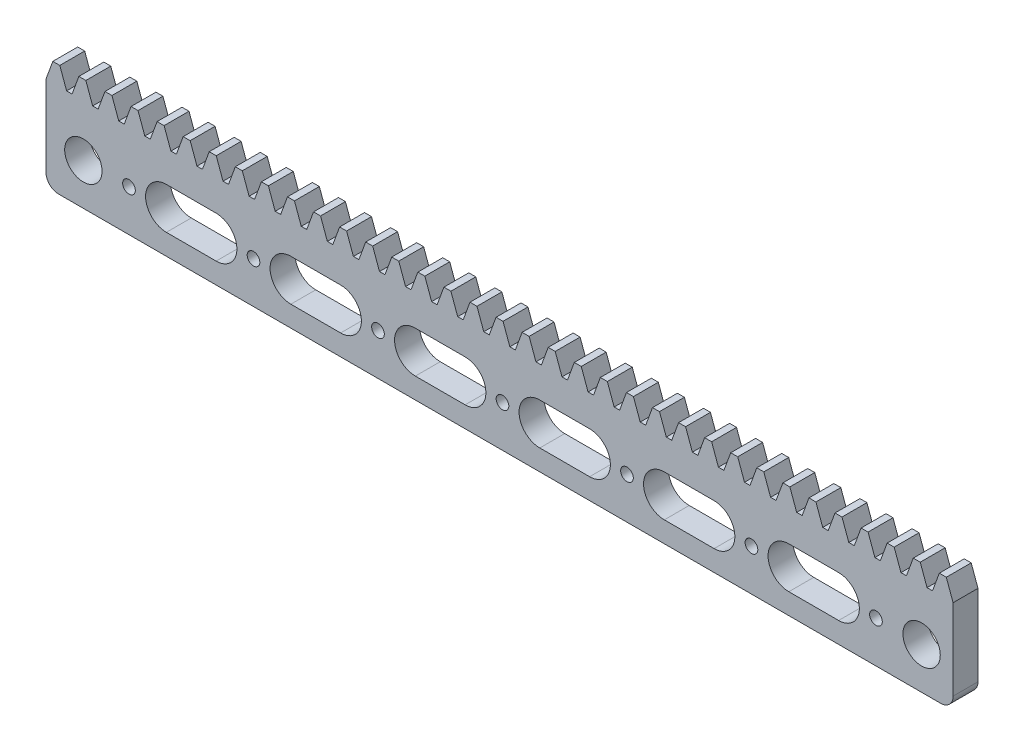
from build123d import *

# Parameters (mm, degrees)
SKETCH_1_W             = 218.58974427
SKETCH_1_H             = 22.5
EXTRUDE_1_DEPTH        = 6
EXTRUDE_2_DEPTH        = 6
PATTERN_LINEAR_1_COUNT = 35
PATTERN_LINEAR_1_PITCH = 6.283185307
SKETCH_3_R             = 1.525
CUT_EXTRUDE_1_DEPTH    = 10
PATTERN_LINEAR_2_COUNT = 7
PATTERN_LINEAR_2_PITCH = 30
FILLET_1_R             = 3
SKETCH_4_R             = 4.5
CUT_EXTRUDE_2_DEPTH    = 10


with BuildPart() as part:
    # 草图1 → 拉伸1 (new body)
    with BuildSketch(Plane.XY):
        with Locations((109.294872135, -11.25)):
            Rectangle(SKETCH_1_W, SKETCH_1_H)
    extrude(amount=EXTRUDE_1_DEPTH)

    # 草图2 → 拉伸2 (add)
    with BuildSketch(Plane.XY.offset(6)):
        Polygon((0, 0), (1.637866054, 4.5), (3.323577771, 4.5), (4.961443825, 0), align=None)
    extrude_2 = extrude(amount=-EXTRUDE_2_DEPTH)

    # 阵列(线性)1: 拉伸2 ×35
    with Locations(*[(i * PATTERN_LINEAR_1_PITCH, 0, 0) for i in range(1, PATTERN_LINEAR_1_COUNT)]):
        add(extrude_2)

    # 草图3 → 切除-拉伸1 (cut)
    with BuildSketch(Plane.XY.offset(6)):
        with Locations((20, -12.5)):
            Circle(SKETCH_3_R)
    cut_extrude_1 = extrude(amount=-CUT_EXTRUDE_1_DEPTH, mode=Mode.SUBTRACT)

    # 阵列(线性)2: 切除-拉伸1 ×7
    with Locations(*[(i * PATTERN_LINEAR_2_PITCH, 0, 0) for i in range(1, PATTERN_LINEAR_2_COUNT)]):
        add(cut_extrude_1, mode=Mode.SUBTRACT)

    # 圆角1
    fillet_1_edges = [part.edges().sort_by_distance(p)[0] for p in [
        (218.58974427, -22.5, 3),
        (0, -22.5, 3),
    ]]
    fillet(fillet_1_edges, radius=FILLET_1_R)

    # 草图4 → 切除-拉伸2 (cut)
    with BuildSketch(Plane.XY.offset(6)):
        with Locations((9, -12.5)):
            Circle(SKETCH_4_R)
        with Locations((211, -12.5)):
            Circle(SKETCH_4_R)
        with BuildLine():
            Line((29, -7.5), (41, -7.5))
            ThreePointArc((41, -7.5), (46, -12.5), (41, -17.5))
            Line((41, -17.5), (29, -17.5))
            ThreePointArc((29, -17.5), (24, -12.5), (29, -7.5))
        make_face()
        with BuildLine():
            Line((71, -7.5), (59, -7.5))
            ThreePointArc((59, -7.5), (54, -12.5), (59, -17.5))
            Line((59, -17.5), (71, -17.5))
            ThreePointArc((71, -17.5), (76, -12.5), (71, -7.5))
        make_face()
        with BuildLine():
            Line((89, -7.5), (101, -7.5))
            ThreePointArc((101, -7.5), (106, -12.5), (101, -17.5))
            Line((101, -17.5), (89, -17.5))
            ThreePointArc((89, -17.5), (84, -12.5), (89, -7.5))
        make_face()
        with BuildLine():
            Line((191, -7.5), (179, -7.5))
            ThreePointArc((179, -7.5), (174, -12.5), (179, -17.5))
            Line((179, -17.5), (191, -17.5))
            ThreePointArc((191, -17.5), (196, -12.5), (191, -7.5))
        make_face()
        with BuildLine():
            Line((149, -7.5), (161, -7.5))
            ThreePointArc((161, -7.5), (166, -12.5), (161, -17.5))
            Line((161, -17.5), (149, -17.5))
            ThreePointArc((149, -17.5), (144, -12.5), (149, -7.5))
        make_face()
        with BuildLine():
            Line((131, -7.5), (119, -7.5))
            ThreePointArc((119, -7.5), (114, -12.5), (119, -17.5))
            Line((119, -17.5), (131, -17.5))
            ThreePointArc((131, -17.5), (136, -12.5), (131, -7.5))
        make_face()
    extrude(amount=-CUT_EXTRUDE_2_DEPTH, mode=Mode.SUBTRACT)


solid = part.part
